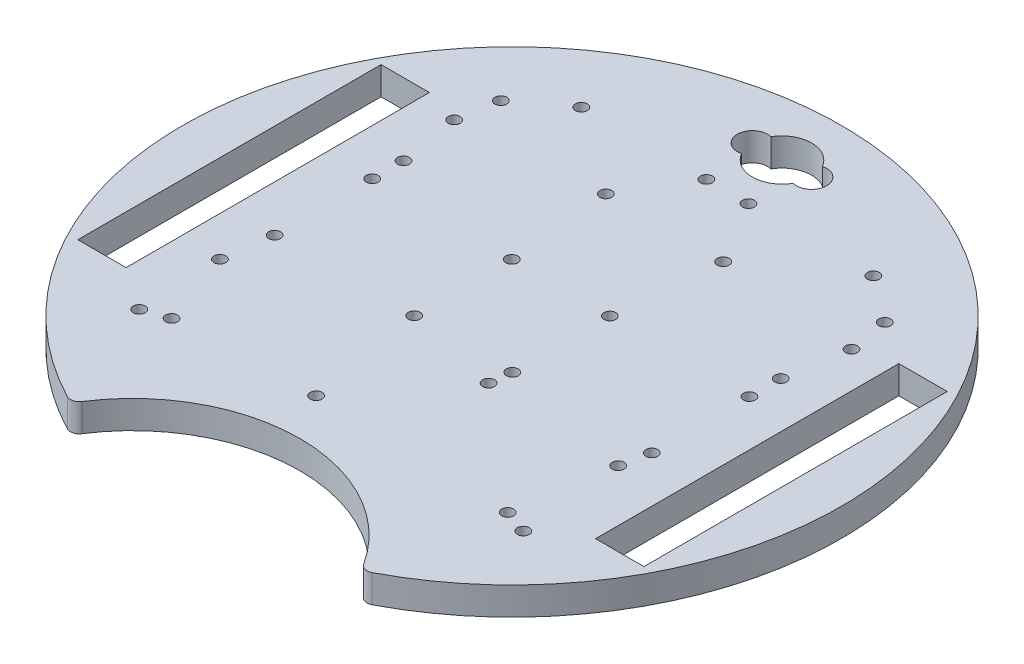
from build123d import *

# Parameters (mm, degrees)
SKETCH1_R           = 1.35
SKETCH1_W           = 11
SKETCH1_H           = 69
BOSS_EXTRUDE1_DEPTH = 6.35
FILLET1_R           = 2


with BuildPart() as part:
    # Sketch1 → Boss-Extrude1 (new body)
    with BuildSketch(Plane(origin=(0, 0, 0), x_dir=(1, 0, 0), z_dir=(0, 1, 0))):
        with BuildLine():
            ThreePointArc((32.995567884, -67.352004425), (0, 75), (-32.995567884, -67.352004425))
            ThreePointArc((-32.995567884, -67.352004425), (0, -48.302004425), (32.995567884, -67.352004425))
        make_face()
        with Locations((-42.910067426, 18.208347884)):
            Circle(SKETCH1_R, mode=Mode.SUBTRACT)
        with Locations((42.910067426, 18.208347884)):
            Circle(SKETCH1_R, mode=Mode.SUBTRACT)
        with Locations((-33.21799214, 49)):
            Circle(SKETCH1_R, mode=Mode.SUBTRACT)
        with Locations((-4.78200786, 49)):
            Circle(SKETCH1_R, mode=Mode.SUBTRACT)
        with Locations((4.78200786, 49)):
            Circle(SKETCH1_R, mode=Mode.SUBTRACT)
        with Locations((33.21799214, 49)):
            Circle(SKETCH1_R, mode=Mode.SUBTRACT)
        with Locations((-42.910067426, 11.1)):
            Circle(SKETCH1_R, mode=Mode.SUBTRACT)
        with Locations((-42.910067426, -11.1)):
            Circle(SKETCH1_R, mode=Mode.SUBTRACT)
        with Locations((-11.160067426, -11.1)):
            Circle(SKETCH1_R, mode=Mode.SUBTRACT)
        with Locations((-11.160067426, 11.1)):
            Circle(SKETCH1_R, mode=Mode.SUBTRACT)
        with Locations((11.160067426, 11.1)):
            Circle(SKETCH1_R, mode=Mode.SUBTRACT)
        with Locations((11.160067426, -11.1)):
            Circle(SKETCH1_R, mode=Mode.SUBTRACT)
        with Locations((42.910067426, -11.1)):
            Circle(SKETCH1_R, mode=Mode.SUBTRACT)
        with Locations((42.910067426, 11.1)):
            Circle(SKETCH1_R, mode=Mode.SUBTRACT)
        with Locations((45.192446616, 32.037646433)):
            Circle(SKETCH1_R, mode=Mode.SUBTRACT)
        with Locations((-45.192446616, 32.037646433)):
            Circle(SKETCH1_R, mode=Mode.SUBTRACT)
        with Locations((13.346873881, 34.693819966)):
            Circle(SKETCH1_R, mode=Mode.SUBTRACT)
        with Locations((-6.55476095, -38.026099982)):
            Circle(SKETCH1_R, mode=Mode.SUBTRACT)
        with Locations((-13.346873881, 34.693819966)):
            Circle(SKETCH1_R, mode=Mode.SUBTRACT)
        with Locations((10.597026674, -15.930038136)):
            Circle(SKETCH1_R, mode=Mode.SUBTRACT)
        with Locations((-38.234289702, -39.23697625)):
            Circle(SKETCH1_R, mode=Mode.SUBTRACT)
        with Locations((-43.68503018, -41.129285651)):
            Circle(SKETCH1_R, mode=Mode.SUBTRACT)
        with Locations((-43.68503018, 41.129285651)):
            Circle(SKETCH1_R, mode=Mode.SUBTRACT)
        with Locations((43.68503018, -41.129285651)):
            Circle(SKETCH1_R, mode=Mode.SUBTRACT)
        with Locations((43.68503018, 41.129285651)):
            Circle(SKETCH1_R, mode=Mode.SUBTRACT)
        with Locations((-44.385223141, -22.074211772)):
            Circle(SKETCH1_R, mode=Mode.SUBTRACT)
        with Locations((41.601681906, -17.457756634)):
            Circle(SKETCH1_R, mode=Mode.SUBTRACT)
        with Locations((38.234289702, -39.23697625)):
            Circle(SKETCH1_R, mode=Mode.SUBTRACT)
        with Locations((58.910067426, 0.102907352)):
            Rectangle(SKETCH1_W, SKETCH1_H, mode=Mode.SUBTRACT)
        with Locations((-58.910067426, 0.102907352)):
            Rectangle(SKETCH1_W, SKETCH1_H, mode=Mode.SUBTRACT)
        with BuildLine():
            ThreePointArc((-5.853899988, 64.744946271), (0.003726822, 68.153564176), (5.857575472, 64.738461857))
            ThreePointArc((5.857575472, 64.738461857), (10.16, 61.422565207), (5.857575472, 58.106668557))
            ThreePointArc((5.857575472, 58.106668557), (0.003726822, 54.691566239), (-5.853899988, 58.100184144))
            ThreePointArc((-5.853899988, 58.100184144), (-10.167207264, 61.422565207), (-5.853899988, 64.744946271))
        make_face(mode=Mode.SUBTRACT)
    extrude(amount=BOSS_EXTRUDE1_DEPTH)

    # Fillet1
    fillet1_edges = [part.edges().sort_by_distance(p)[0] for p in [
        (-32.995567884, 3.175, 67.352004425),
        (32.995567884, 3.175, 67.352004425),
    ]]
    fillet(fillet1_edges, radius=FILLET1_R)


solid = part.part
